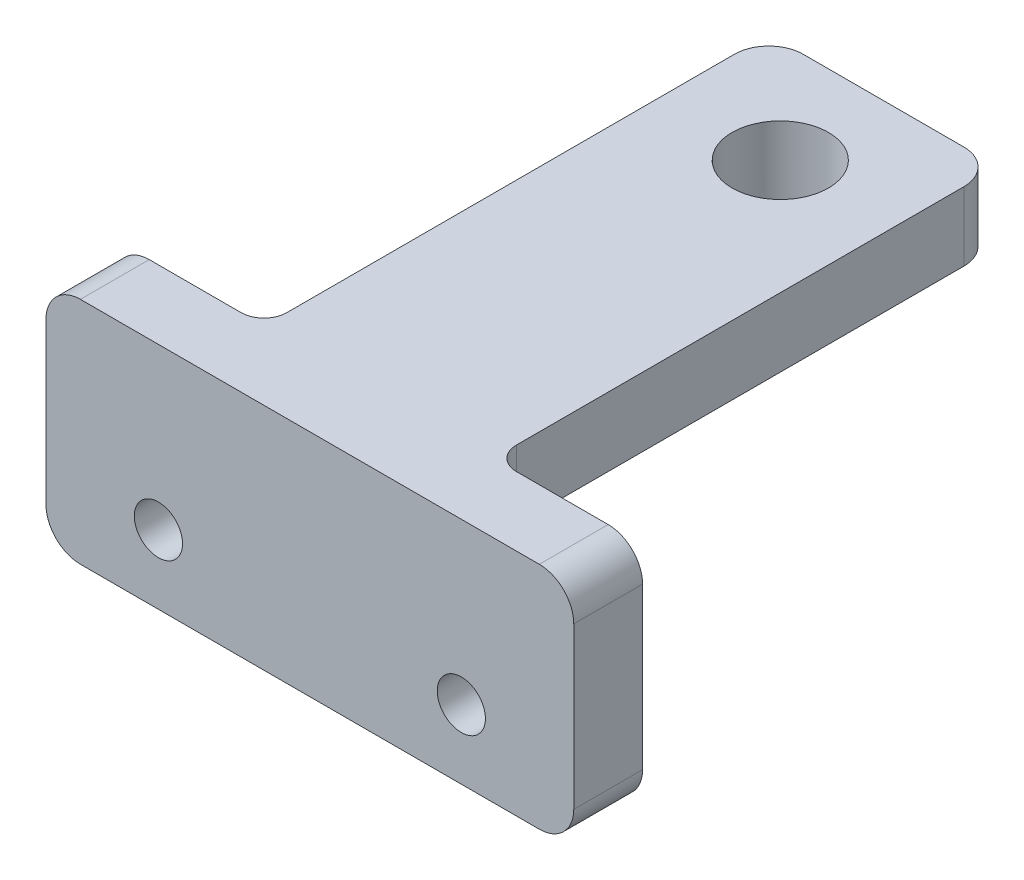
from build123d import *

# Parameters (mm, degrees)
SKETCH2_W           = 23
SKETCH2_H           = 10
SKETCH2_R           = 1.05
BOSS_EXTRUDE1_DEPTH = 3
SKETCH3_W           = 10
SKETCH3_H           = 3
BOSS_EXTRUDE2_DEPTH = 25
SKETCH4_R           = 2.1
CUT_EXTRUDE1_DEPTH  = 11
FILLET1_R           = 1.5
FILLET2_R           = 1


with BuildPart() as part:
    # Sketch2 → Boss-Extrude1 (new body)
    with BuildSketch(Plane.XY):
        with Locations((11.5, 5)):
            Rectangle(SKETCH2_W, SKETCH2_H)
        with Locations((4.9, 3)):
            Circle(SKETCH2_R, mode=Mode.SUBTRACT)
        with Locations((18.1, 3)):
            Circle(SKETCH2_R, mode=Mode.SUBTRACT)
    extrude(amount=BOSS_EXTRUDE1_DEPTH)

    # Sketch3 → Boss-Extrude2 (add)
    with BuildSketch(Plane.XY.offset(3)):
        with Locations((11.5, 8.5)):
            Rectangle(SKETCH3_W, SKETCH3_H)
    extrude(amount=-BOSS_EXTRUDE2_DEPTH)

    # Sketch4 → Cut-Extrude1 (cut, through all)
    with BuildSketch(Plane(origin=(0, 10, 0), x_dir=(1, 0, 0), z_dir=(0, 1, 0))):
        with Locations((11.5, 17.5)):
            Circle(SKETCH4_R)
    extrude(amount=-CUT_EXTRUDE1_DEPTH, mode=Mode.SUBTRACT)

    # Fillet1
    fillet1_edges = [part.edges().sort_by_distance(p)[0] for p in [
        (6.5, 8.5, -22),
        (16.5, 8.5, -22),
        (0, 10, 1.5),
        (23, 10, 1.5),
        (23, 0, 1.5),
        (0, 0, 1.5),
    ]]
    fillet(fillet1_edges, radius=FILLET1_R)

    # Fillet2
    fillet2_edges = [part.edges().sort_by_distance(p)[0] for p in [
        (11.5, 7, 0),
        (6.5, 8.5, 0),
        (16.5, 8.5, 0),
    ]]
    fillet(fillet2_edges, radius=FILLET2_R)


solid = part.part
